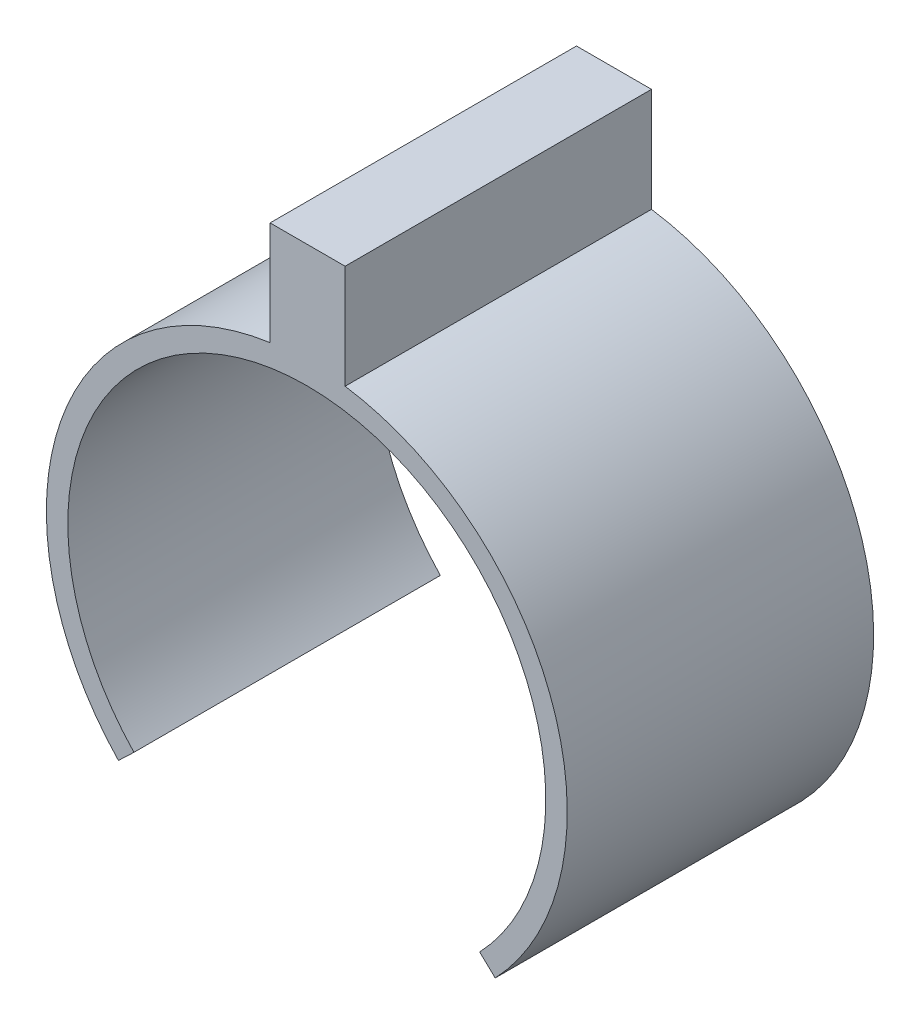
from build123d import *

# Parameters (mm, degrees)
SKETCH1_R           = 4.25
SKETCH1_R_2         = 3.9
BOSS_EXTRUDE1_DEPTH = 5
CUT_EXTRUDE1_DEPTH  = 5
SKETCH3_W           = 1.224263259
SKETCH3_H           = 5
BOSS_EXTRUDE2_DEPTH = 2


with BuildPart() as part:
    # Sketch1 → Boss-Extrude1 (new body)
    with BuildSketch(Plane.XY):
        Circle(SKETCH1_R)
        Circle(SKETCH1_R_2, mode=Mode.SUBTRACT)
    extrude(amount=BOSS_EXTRUDE1_DEPTH)

    # Sketch2 → Cut-Extrude1 (cut)
    with BuildSketch(Plane.XY.offset(5)):
        with BuildLine():
            Line((-3.074069072, -2.934723044), (-2.820910442, -2.69303997))
            ThreePointArc((-2.820910442, -2.69303997), (0, -3.9), (2.820910442, -2.69303997))
            Line((2.820910442, -2.69303997), (3.074069072, -2.934723044))
            ThreePointArc((3.074069072, -2.934723044), (0, -4.25), (-3.074069072, -2.934723044))
        make_face()
    extrude(amount=-CUT_EXTRUDE1_DEPTH, mode=Mode.SUBTRACT)

    # Sketch3 → Boss-Extrude2 (add)
    with BuildSketch(Plane(origin=(0, 3.9, 0), x_dir=(1, 0, 0), z_dir=(0, 1, 0))):
        with Locations((0.012871952, -2.5)):
            Rectangle(SKETCH3_W, SKETCH3_H)
    extrude(amount=BOSS_EXTRUDE2_DEPTH)


solid = part.part
